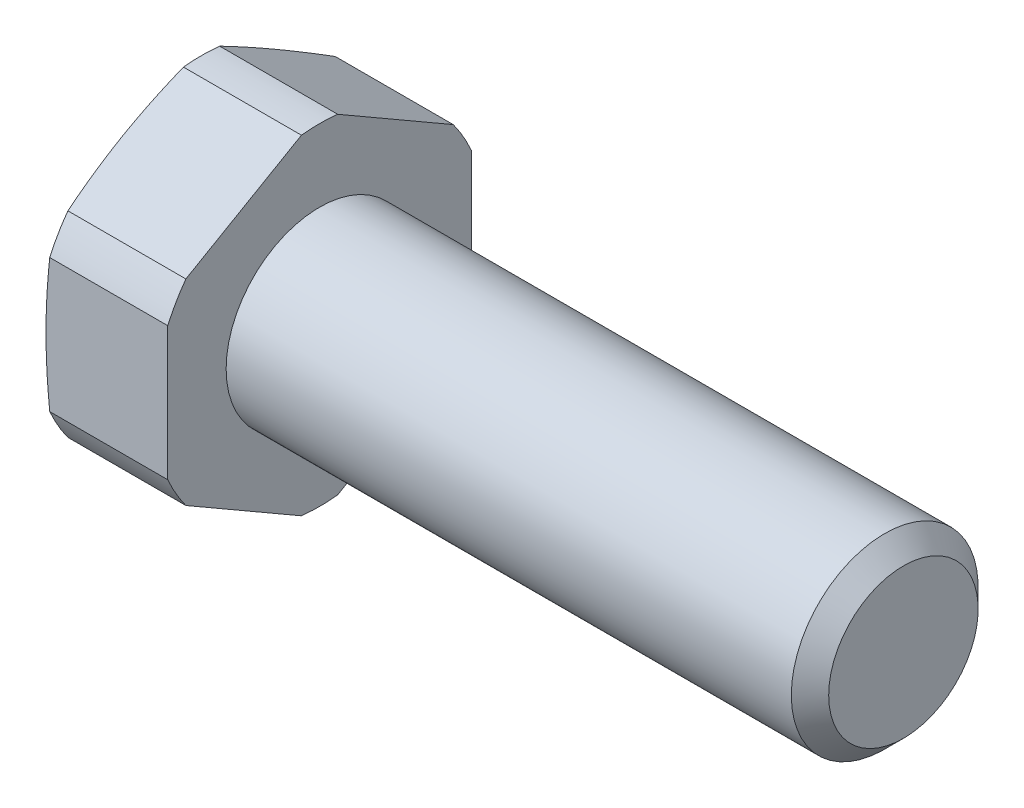
from build123d import *

# Parameters (mm, degrees)
SKETCH_2_OUTSIDE_W  = 23.47
SKETCH_2_OUTSIDE_H  = 23.47
CUT_EXTRUDE_1_DEPTH = 30.3


with BuildPart() as part:
    # Эскиз1 → Повернуть1 (revolve)
    with BuildSketch(Plane.XY):
        Polygon((-5.3, 0), (-5.3, 6.175), (-5.052146997, 7.1), (0, 7.1), (0, 4), (24.2, 4), (25, 3.2), (25, 0), align=None)
    revolve(axis=Axis((-1000, 0, 0), (1, 0, 0)))

    # Эскиз2 outside → Вырез-Вытянуть1 (cut)
    with BuildSketch(Plane.ZY.offset(5.3)):
        Rectangle(SKETCH_2_OUTSIDE_W, SKETCH_2_OUTSIDE_H)
        Polygon((0, 7.505553499), (-6.5, 3.75277675), (-6.5, -3.75277675), (0, -7.505553499), (6.5, -3.75277675), (6.5, 3.75277675), align=None, mode=Mode.SUBTRACT)
    extrude(amount=-CUT_EXTRUDE_1_DEPTH, mode=Mode.SUBTRACT)


solid = part.part
